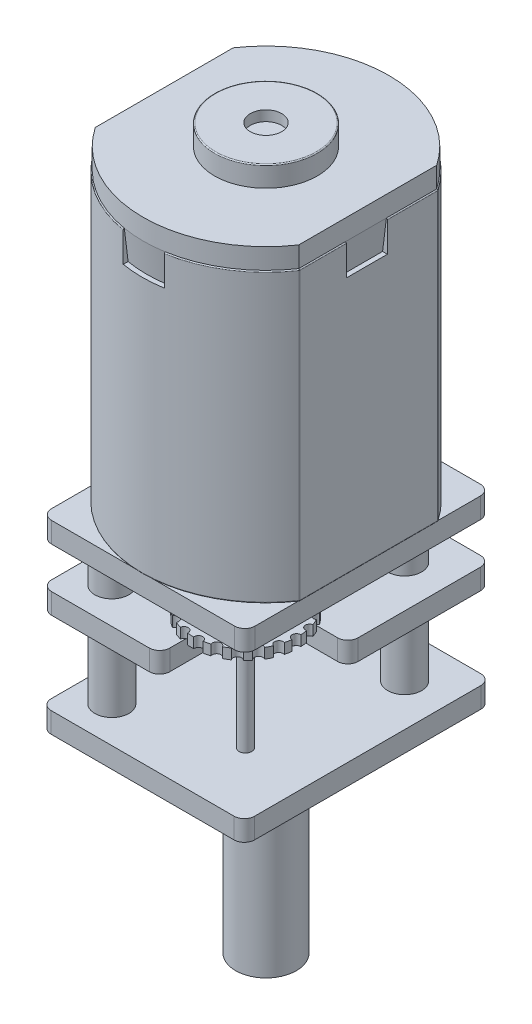
from build123d import *

# Parameters (mm, degrees)
BOSS_EXTRUDE1_DEPTH           = 14
FILLET2_R                     = 0.05
SKETCH2_W                     = 2
SKETCH2_H                     = 15.77966069
SKETCH2_W_2                   = 6.959998492
SKETCH2_H_2                   = 2
CUT_EXTRUDE1_DEPTH            = 1.5
BOSS_EXTRUDE2_DEPTH           = 1
BOSS_EXTRUDE2_OTHER_WAY_DEPTH = 1.5
BOSS_EXTRUDE2_OTHER_WAY_TAPER = 7
SKETCH4_R                     = 2.5
BOSS_EXTRUDE3_DEPTH           = 1
FILLET3_R                     = 0.05
SKETCH5_R                     = 0.76366265
CUT_EXTRUDE2_DEPTH            = 0.5
BOSS_EXTRUDE4_DEPTH           = 1
SKETCH7_R                     = 0.827932511
BOSS_EXTRUDE5_DEPTH           = 2
BOSS_EXTRUDE6_DEPTH           = 1
SKETCH9_R                     = 0.827932511
BOSS_EXTRUDE7_DEPTH           = 4
BOSS_EXTRUDE8_DEPTH           = 1
SKETCH11_R                    = 0.188939958
SKETCH11_R_2                  = 1.002662162
SKETCH11_R_3                  = 0.993241693
CUT_EXTRUDE3_DEPTH            = 0.07
BOSS_EXTRUDE9_DEPTH           = 10
SKETCH14_R                    = 2.02
SKETCH14_R_2                  = 1.574936399
BOSS_EXTRUDE10_DEPTH          = 1
BOSS_EXTRUDE11_START          = 2
BOSS_EXTRUDE11_DEPTH          = 0.5
BOSS_EXTRUDE12_START          = 1
BOSS_EXTRUDE12_DEPTH          = 0.5
BOSS_EXTRUDE13_START          = -3
SKETCH17_R                    = 0.310512929
BOSS_EXTRUDE13_DEPTH          = 7
SKETCH18_R                    = 0.309045019
BOSS_EXTRUDE14_DEPTH          = 7


with BuildPart() as part:
    # Sketch1 → Boss-Extrude1 (new body)
    with BuildSketch(Plane(origin=(0, 0, 0), x_dir=(1, 0, 0), z_dir=(0, 1, 0))):
        with BuildLine():
            Line((-5, -3.37059342), (-5, 3.37059342))
            ThreePointArc((-5, 3.37059342), (0, 6.03), (5, 3.37059342))
            Line((5, 3.37059342), (5, -3.37059342))
            ThreePointArc((5, -3.37059342), (0, -6.03), (-5, -3.37059342))
        make_face()
    extrude(amount=BOSS_EXTRUDE1_DEPTH)

    # Fillet2
    fillet2_edges = [part.edges().sort_by_distance(p)[0] for p in [
        (0, 14, 6.03),
        (5, 14, 0),
        (0, 14, -6.03),
        (5, 0, 0),
        (0, 0, 6.03),
        (-5, 0, 0),
        (0, 0, -6.03),
        (-5, 14, 0),
        (5, 7, -3.37059342),
        (5, 7, 3.37059342),
        (-5, 7, 3.37059342),
        (-5, 7, -3.37059342),
    ]]
    fillet(fillet2_edges, radius=FILLET2_R)

    # Sketch2 → Cut-Extrude1 (cut)
    with BuildSketch(Plane(origin=(0, 14, 0), x_dir=(1, 0, 0), z_dir=(0, 1, 0))):
        Rectangle(SKETCH2_W, SKETCH2_H)
        with Locations((3.479999246, -0.091907088)):
            Rectangle(SKETCH2_W_2, SKETCH2_H_2)
    extrude(amount=-CUT_EXTRUDE1_DEPTH, mode=Mode.SUBTRACT)

    # Sketch3 → Boss-Extrude2 (add)
    with BuildSketch(Plane(origin=(0, 14, 0), x_dir=(1, 0, 0), z_dir=(0, 1, 0))):
        with BuildLine():
            ThreePointArc((4.95, 3.355279422), (0, 5.98), (-4.95, 3.355279422))
            Line((-4.95, 3.355279422), (-4.95, -3.355279422))
            ThreePointArc((-4.95, -3.355279422), (0, -5.98), (4.95, -3.355279422))
            Line((4.95, -3.355279422), (4.95, 3.355279422))
        make_face()
    extrude(amount=BOSS_EXTRUDE2_DEPTH)

    # Sketch3 → Boss-Extrude2 other way (add)
    with BuildSketch(Plane(origin=(0, 14, 0), x_dir=(1, 0, 0), z_dir=(0, 1, 0))):
        with BuildLine():
            ThreePointArc((4.95, 3.355279422), (0, 5.98), (-4.95, 3.355279422))
            Line((-4.95, 3.355279422), (-4.95, -3.355279422))
            ThreePointArc((-4.95, -3.355279422), (0, -5.98), (4.95, -3.355279422))
            Line((4.95, -3.355279422), (4.95, 3.355279422))
        make_face()
    extrude(amount=-BOSS_EXTRUDE2_OTHER_WAY_DEPTH, taper=BOSS_EXTRUDE2_OTHER_WAY_TAPER)

    # Sketch4 → Boss-Extrude3 (add)
    with BuildSketch(Plane(origin=(0, 15, 0), x_dir=(1, 0, 0), z_dir=(0, 1, 0))):
        with Locations(Location((0, 0, 0), (0, 0, 270))):  # turned: the seam where the file's is
            Circle(SKETCH4_R)
    extrude(amount=BOSS_EXTRUDE3_DEPTH)

    # Fillet3
    fillet3_edges = [part.edges().sort_by_distance(p)[0] for p in [
        (0, 16, -2.5),
    ]]
    fillet(fillet3_edges, radius=FILLET3_R)

    # Sketch5 → Cut-Extrude2 (cut)
    with BuildSketch(Plane(origin=(0, 16, 0), x_dir=(1, 0, 0), z_dir=(0, 1, 0))):
        with Locations(Location((0, 0, 0), (0, 0, 270))):  # turned: the seam where the file's is
            Circle(SKETCH5_R)
    extrude(amount=-CUT_EXTRUDE2_DEPTH, mode=Mode.SUBTRACT)

    # Sketch6 → Boss-Extrude4 (add)
    with BuildSketch(Plane(origin=(0, 0, 0), x_dir=(-1, 0, 0), z_dir=(0, -1, 0))):
        with BuildLine():
            Line((-4.45, -5.98), (4.45, -5.98))
            ThreePointArc((4.45, -5.98), (4.803553391, -5.833553391), (4.95, -5.48))
            Line((4.95, -5.48), (4.95, 5.48))
            ThreePointArc((4.95, 5.48), (4.803553391, 5.833553391), (4.45, 5.98))
            Line((4.45, 5.98), (-4.45, 5.98))
            ThreePointArc((-4.45, 5.98), (-4.803553391, 5.833553391), (-4.95, 5.48))
            Line((-4.95, 5.48), (-4.95, -5.48))
            ThreePointArc((-4.95, -5.48), (-4.803553391, -5.833553391), (-4.45, -5.98))
        make_face()
    extrude(amount=BOSS_EXTRUDE4_DEPTH)

    # Sketch7 → Boss-Extrude5 (add)
    with BuildSketch(Plane.XZ.offset(1)):
        with Locations(Location((2.896257025, -3.849803677, 0), (0, 0, 90))):  # turned: the seam where the file's is
            Circle(SKETCH7_R)
        with Locations(Location((-3.263294102, 4.236052212, 0), (0, 0, 90))):  # turned: the seam where the file's is
            Circle(SKETCH7_R)
    extrude(amount=BOSS_EXTRUDE5_DEPTH)

    # Sketch8 → Boss-Extrude6 (add)
    with BuildSketch(Plane.XZ.offset(3)):
        with BuildLine():
            Line((0.299765268, 5.98), (-4.45, 5.98))
            ThreePointArc((-4.45, 5.98), (-4.803553391, 5.833553391), (-4.95, 5.48))
            Line((-4.95, 5.48), (-4.95, -5.48))
            ThreePointArc((-4.95, -5.48), (-4.803553391, -5.833553391), (-4.45, -5.98))
            Line((-4.45, -5.98), (4.45, -5.98))
            ThreePointArc((4.45, -5.98), (4.803553391, -5.833553391), (4.95, -5.48))
            Line((4.95, -5.48), (4.95, 0.466181071))
            ThreePointArc((4.95, 0.466181071), (4.803553391, 0.819734462), (4.45, 0.966181071))
            Line((4.45, 0.966181071), (0.799765268, 0.966181071))
            Line((0.799765268, 0.966181071), (0.799765268, 5.48))
            ThreePointArc((0.799765268, 5.48), (0.653318659, 5.833553391), (0.299765268, 5.98))
        make_face()
    extrude(amount=BOSS_EXTRUDE6_DEPTH)

    # Sketch9 → Boss-Extrude7 (add)
    with BuildSketch(Plane.XZ.offset(4)):
        with Locations(Location((2.896257025, -3.849803677, 0), (0, 0, 90))):  # turned: the seam where the file's is
            Circle(SKETCH9_R)
        with Locations(Location((-3.263294102, 4.236052212, 0), (0, 0, 90))):  # turned: the seam where the file's is
            Circle(SKETCH9_R)
    extrude(amount=BOSS_EXTRUDE7_DEPTH)

    # Sketch10 → Boss-Extrude8 (add)
    with BuildSketch(Plane.XZ.offset(8)):
        with BuildLine():
            Line((-4.45, 6.004092009), (4.45, 6.004092009))
            ThreePointArc((4.45, 6.004092009), (4.803553391, 5.857645399), (4.95, 5.504092009))
            Line((4.95, 5.504092009), (4.95, -5.504092009))
            ThreePointArc((4.95, -5.504092009), (4.803553391, -5.857645399), (4.45, -6.004092009))
            Line((4.45, -6.004092009), (-4.45, -6.004092009))
            ThreePointArc((-4.45, -6.004092009), (-4.803553391, -5.857645399), (-4.95, -5.504092009))
            Line((-4.95, -5.504092009), (-4.95, 5.504092009))
            ThreePointArc((-4.95, 5.504092009), (-4.803553391, 5.857645399), (-4.45, 6.004092009))
        make_face()
    extrude(amount=BOSS_EXTRUDE8_DEPTH)

    # Sketch11 → Cut-Extrude3 (cut)
    with BuildSketch(Plane.XZ.offset(9)):
        with Locations(Location((0, -4.702505629, 0), (0, 0, 270))):  # turned: the seam where the file's is
            Circle(SKETCH11_R)
        with Locations(Location((0, 4.702505629, 0), (0, 0, 90))):  # turned: the seam where the file's is
            Circle(SKETCH11_R)
        with Locations(Location((2.896257025, -3.849803677, 0), (0, 0, 270))):  # turned: the seam where the file's is
            Circle(SKETCH11_R_2)
        with Locations(Location((-3.263294102, 4.236052212, 0), (0, 0, 270))):  # turned: the seam where the file's is
            Circle(SKETCH11_R_3)
    extrude(amount=-CUT_EXTRUDE3_DEPTH, mode=Mode.SUBTRACT)

    # Sketch13 → Boss-Extrude9 (add)
    with BuildSketch(Plane(origin=(0, -9, 0), x_dir=(-1, 0, 0), z_dir=(0, -1, 0))):
        with BuildLine():
            Line((0.93, 1.151303609), (0.93, -1.151303609))
            ThreePointArc((0.93, -1.151303609), (-1.48, 0), (0.93, 1.151303609))
        make_face()
    extrude(amount=BOSS_EXTRUDE9_DEPTH)

    # Sketch14 → Boss-Extrude10 (add)
    with BuildSketch(Plane.XZ.offset(9)):
        with Locations(Location((0, 0, 0), (0, 0, 270))):  # turned: the seam where the file's is
            Circle(SKETCH14_R)
        with Locations(Location((0, 0, 0), (0, 0, 270))):  # turned: the seam where the file's is
            Circle(SKETCH14_R_2, mode=Mode.SUBTRACT)
    extrude(amount=BOSS_EXTRUDE10_DEPTH)



with BuildPart() as body_2:
    # Sketch15 → Boss-Extrude11 (new body)
    with BuildSketch(Plane.XZ.offset(4).offset(BOSS_EXTRUDE11_START)):
        with BuildLine():
            ThreePointArc((0.455644587, -1.919539049), (0.43202519, -1.762564621), (0.398810222, -1.607337003))
            ThreePointArc((0.398810222, -1.607337003), (0.133101961, -1.474854904), (0.265584061, -1.209146643))
            ThreePointArc((0.265584061, -1.209146643), (0.198696609, -1.065185134), (0.123094407, -0.925603064))
            ThreePointArc((0.123094407, -0.925603064), (-0.169175323, -0.873346088), (-0.116918347, -0.581076358))
            ThreePointArc((-0.116918347, -0.581076358), (-0.221655032, -0.461790675), (-0.333519627, -0.349162261))
            ThreePointArc((-0.333519627, -0.349162261), (-0.62867287, -0.381363958), (-0.660874568, -0.086210714))
            ThreePointArc((-0.660874568, -0.086210714), (-0.794975341, -0.001264673), (-0.934039724, 0.0752856))
            ThreePointArc((-0.934039724, 0.0752856), (-1.208164922, -0.03876598), (-1.322216502, 0.235359217))
            ThreePointArc((-1.322216502, 0.235359217), (-1.474817317, 0.279083793), (-1.62981532, 0.313354278))
            ThreePointArc((-1.62981532, 0.313354278), (-1.860704477, 0.126692595), (-2.04736616, 0.357581753))
            ThreePointArc((-2.04736616, 0.357581753), (-2.206104206, 0.356542558), (-2.364478813, 0.345756864))
            ThreePointArc((-2.364478813, 0.345756864), (-2.533426664, 0.101607299), (-2.777576229, 0.27055515))
            ThreePointArc((-2.777576229, 0.27055515), (-2.929591494, 0.224836374), (-3.078512135, 0.169868293))
            ThreePointArc((-3.078512135, 0.169868293), (-3.17183153, -0.111989609), (-3.453689433, -0.018670214))
            ThreePointArc((-3.453689433, -0.018670214), (-3.586666544, -0.105364708), (-3.714068554, -0.200061988))
            ThreePointArc((-3.714068554, -0.200061988), (-3.72419931, -0.496793777), (-4.020931099, -0.486663021))
            ThreePointArc((-4.020931099, -0.486663021), (-4.124097042, -0.607309759), (-4.219659069, -0.734064428))
            ThreePointArc((-4.219659069, -0.734064428), (-4.145780453, -1.021630658), (-4.433346683, -1.095509275))
            ThreePointArc((-4.433346683, -1.095509275), (-4.498343565, -1.240334178), (-4.554323742, -1.388877326))
            ThreePointArc((-4.554323742, -1.388877326), (-4.40242096, -1.643981092), (-4.657524725, -1.795883875))
            ThreePointArc((-4.657524725, -1.795883875), (-4.679086888, -1.953154089), (-4.690950033, -2.111451635))
            ThreePointArc((-4.690950033, -2.111451635), (-4.473329344, -2.313425946), (-4.675303655, -2.531046635))
            ThreePointArc((-4.675303655, -2.531046635), (-4.651684259, -2.688021064), (-4.618469291, -2.843248681))
            ThreePointArc((-4.618469291, -2.843248681), (-4.35276103, -2.975730781), (-4.48524313, -3.241439042))
            ThreePointArc((-4.48524313, -3.241439042), (-4.418355678, -3.38540055), (-4.342753476, -3.524982621))
            ThreePointArc((-4.342753476, -3.524982621), (-4.050483746, -3.577239597), (-4.102740722, -3.869509327))
            ThreePointArc((-4.102740722, -3.869509327), (-3.998004037, -3.98879501), (-3.886139442, -4.101423424))
            ThreePointArc((-3.886139442, -4.101423424), (-3.590986199, -4.069221727), (-3.558784501, -4.364374971))
            ThreePointArc((-3.558784501, -4.364374971), (-3.424683728, -4.449321011), (-3.285619344, -4.525871285))
            ThreePointArc((-3.285619344, -4.525871285), (-3.011494147, -4.411819705), (-2.897442567, -4.685944902))
            ThreePointArc((-2.897442567, -4.685944902), (-2.744841752, -4.729669478), (-2.589843749, -4.763939963))
            ThreePointArc((-2.589843749, -4.763939963), (-2.358954591, -4.57727828), (-2.172292909, -4.808167437))
            ThreePointArc((-2.172292909, -4.808167437), (-2.013554863, -4.807128243), (-1.855180256, -4.796342549))
            ThreePointArc((-1.855180256, -4.796342549), (-1.686232405, -4.552192983), (-1.44208284, -4.721140834))
            ThreePointArc((-1.44208284, -4.721140834), (-1.290067575, -4.675422059), (-1.141146934, -4.620453978))
            ThreePointArc((-1.141146934, -4.620453978), (-1.047827539, -4.338596076), (-0.765969636, -4.43191547))
            ThreePointArc((-0.765969636, -4.43191547), (-0.632992525, -4.345220977), (-0.505590515, -4.250523697))
            ThreePointArc((-0.505590515, -4.250523697), (-0.495459759, -3.953791908), (-0.19872797, -3.963922664))
            ThreePointArc((-0.19872797, -3.963922664), (-0.095562027, -3.843275925), (0, -3.716521256))
            ThreePointArc((0, -3.716521256), (-0.073878616, -3.428955026), (0.213687614, -3.35507641))
            ThreePointArc((0.213687614, -3.35507641), (0.278684496, -3.210251507), (0.334664673, -3.061708358))
            ThreePointArc((0.334664673, -3.061708358), (0.182761891, -2.806604593), (0.437865656, -2.65470181))
            ThreePointArc((0.437865656, -2.65470181), (0.459427819, -2.497431595), (0.471290964, -2.33913405))
            ThreePointArc((0.471290964, -2.33913405), (0.253670275, -2.137159738), (0.455644587, -1.919539049))
        make_face()
    extrude(amount=BOSS_EXTRUDE11_DEPTH)


with BuildPart() as body_3:
    # Sketch16 → Boss-Extrude12 (new body)
    with BuildSketch(Plane.XZ.offset(1).offset(BOSS_EXTRUDE12_START)):
        with BuildLine():
            ThreePointArc((4.413684793, 3.154023664), (4.390065397, 3.310998093), (4.356850429, 3.46622571))
            ThreePointArc((4.356850429, 3.46622571), (4.091142168, 3.59870781), (4.223624267, 3.864416071))
            ThreePointArc((4.223624267, 3.864416071), (4.156736815, 4.00837758), (4.081134614, 4.14795965))
            ThreePointArc((4.081134614, 4.14795965), (3.788864883, 4.200216626), (3.841121859, 4.492486356))
            ThreePointArc((3.841121859, 4.492486356), (3.736385175, 4.611772039), (3.62452058, 4.724400453))
            ThreePointArc((3.62452058, 4.724400453), (3.329367336, 4.692198756), (3.297165639, 4.987352))
            ThreePointArc((3.297165639, 4.987352), (3.163064866, 5.072298041), (3.024000482, 5.148848314))
            ThreePointArc((3.024000482, 5.148848314), (2.749875285, 5.034796734), (2.635823705, 5.308921931))
            ThreePointArc((2.635823705, 5.308921931), (2.48322289, 5.352646507), (2.328224887, 5.386916992))
            ThreePointArc((2.328224887, 5.386916992), (2.097335729, 5.200255309), (1.910674047, 5.431144467))
            ThreePointArc((1.910674047, 5.431144467), (1.751936001, 5.430105272), (1.593561394, 5.419319578))
            ThreePointArc((1.593561394, 5.419319578), (1.424613543, 5.175170012), (1.180463977, 5.344117864))
            ThreePointArc((1.180463977, 5.344117864), (1.028448713, 5.298399088), (0.879528071, 5.243431007))
            ThreePointArc((0.879528071, 5.243431007), (0.786208677, 4.961573105), (0.504350774, 5.054892499))
            ThreePointArc((0.504350774, 5.054892499), (0.371373663, 4.968198006), (0.243971652, 4.873500726))
            ThreePointArc((0.243971652, 4.873500726), (0.233840896, 4.576768937), (-0.062890892, 4.586899693))
            ThreePointArc((-0.062890892, 4.586899693), (-0.166056835, 4.466252955), (-0.261618862, 4.339498286))
            ThreePointArc((-0.261618862, 4.339498286), (-0.187740246, 4.051932055), (-0.475306476, 3.978053439))
            ThreePointArc((-0.475306476, 3.978053439), (-0.540303359, 3.833228536), (-0.596283536, 3.684685388))
            ThreePointArc((-0.596283536, 3.684685388), (-0.444380753, 3.429581622), (-0.699484519, 3.277678839))
            ThreePointArc((-0.699484519, 3.277678839), (-0.721046681, 3.120408625), (-0.732909826, 2.962111079))
            ThreePointArc((-0.732909826, 2.962111079), (-0.515289137, 2.760136767), (-0.717263449, 2.542516079))
            ThreePointArc((-0.717263449, 2.542516079), (-0.693644052, 2.38554165), (-0.660429084, 2.230314033))
            ThreePointArc((-0.660429084, 2.230314033), (-0.394720823, 2.097831933), (-0.527202923, 1.832123672))
            ThreePointArc((-0.527202923, 1.832123672), (-0.460315471, 1.688162163), (-0.384713269, 1.548580093))
            ThreePointArc((-0.384713269, 1.548580093), (-0.092443539, 1.496323117), (-0.144700515, 1.204053387))
            ThreePointArc((-0.144700515, 1.204053387), (-0.039963831, 1.084767704), (0.071900764, 0.97213929))
            ThreePointArc((0.071900764, 0.97213929), (0.367054008, 1.004340987), (0.399255705, 0.709187743))
            ThreePointArc((0.399255705, 0.709187743), (0.533356478, 0.624241703), (0.672420862, 0.547691429))
            ThreePointArc((0.672420862, 0.547691429), (0.946546059, 0.661743009), (1.06059764, 0.387617812))
            ThreePointArc((1.06059764, 0.387617812), (1.213198454, 0.343893236), (1.368196458, 0.309622751))
            ThreePointArc((1.368196458, 0.309622751), (1.599085615, 0.496284434), (1.785747298, 0.265395276))
            ThreePointArc((1.785747298, 0.265395276), (1.944485344, 0.266434471), (2.10285995, 0.277220165))
            ThreePointArc((2.10285995, 0.277220165), (2.271807802, 0.521369731), (2.515957367, 0.35242188))
            ThreePointArc((2.515957367, 0.35242188), (2.667972632, 0.398140655), (2.816893273, 0.453108736))
            ThreePointArc((2.816893273, 0.453108736), (2.910212668, 0.734966638), (3.19207057, 0.641647244))
            ThreePointArc((3.19207057, 0.641647244), (3.325047681, 0.728341737), (3.452449692, 0.823039017))
            ThreePointArc((3.452449692, 0.823039017), (3.462580448, 1.119770806), (3.759312237, 1.10964005))
            ThreePointArc((3.759312237, 1.10964005), (3.862478179, 1.230286788), (3.958040207, 1.357041457))
            ThreePointArc((3.958040207, 1.357041457), (3.88416159, 1.644607688), (4.17172782, 1.718486304))
            ThreePointArc((4.17172782, 1.718486304), (4.236724703, 1.863311207), (4.29270488, 2.011854355))
            ThreePointArc((4.29270488, 2.011854355), (4.140802097, 2.266958121), (4.395905863, 2.418860904))
            ThreePointArc((4.395905863, 2.418860904), (4.417468025, 2.576131118), (4.429331171, 2.734428664))
            ThreePointArc((4.429331171, 2.734428664), (4.211710482, 2.936402976), (4.413684793, 3.154023664))
        make_face()
    extrude(amount=BOSS_EXTRUDE12_DEPTH)


with BuildPart() as part_1:
    add(part.part)

    add(body_2.part)  # Boss-Extrude13 merges body 2
    # Sketch17 → Boss-Extrude13 (add)
    with BuildSketch(Plane.XZ.offset(4).offset(BOSS_EXTRUDE13_START)):
        with Locations(Location((-2.109829534, -2.225292842, 0), (0, 0, 90))):  # turned: the seam where the file's is
            Circle(SKETCH17_R)
    extrude(amount=BOSS_EXTRUDE13_DEPTH)


    add(body_3.part)  # Boss-Extrude14 merges body 3
    # Sketch18 → Boss-Extrude14 (add)
    with BuildSketch(Plane(origin=(0, -1, 0), x_dir=(-1, 0, 0), z_dir=(0, -1, 0))):
        with Locations(Location((-1.848210672, -2.848269872, 0), (0, 0, 270))):  # turned: the seam where the file's is
            Circle(SKETCH18_R)
    extrude(amount=BOSS_EXTRUDE14_DEPTH)


solid = part_1.part
